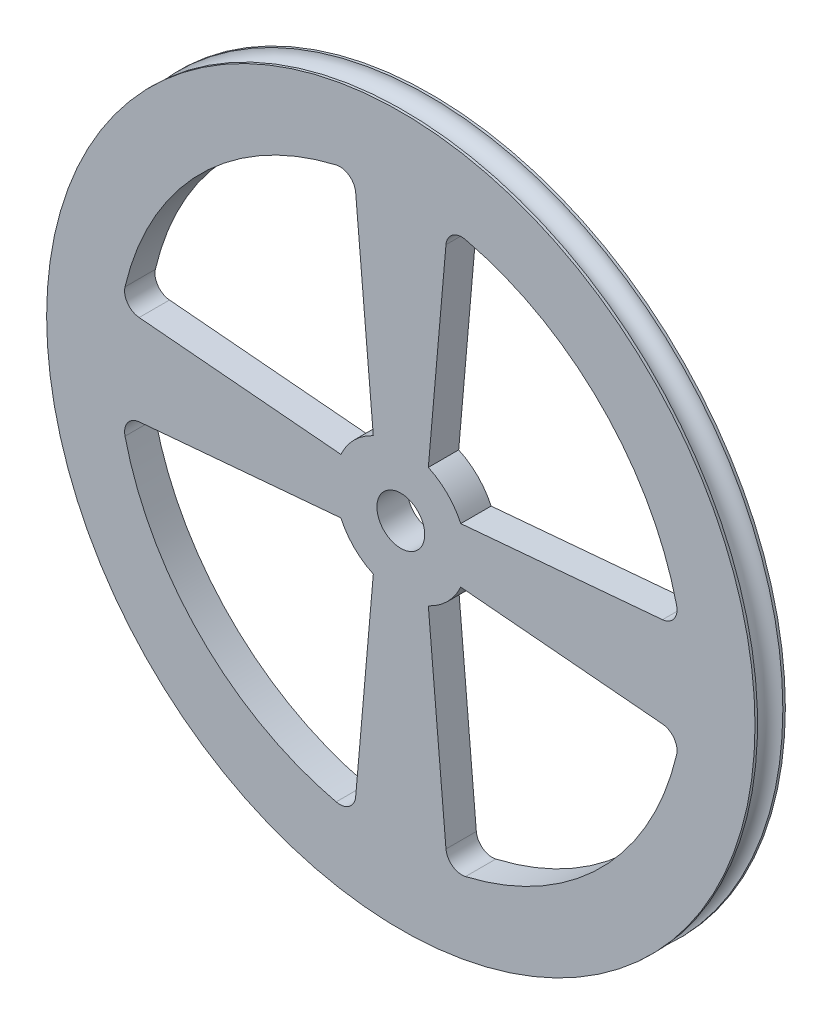
from build123d import *

# Parameters (mm, degrees)
SKETCH1_R           = 44.45
SKETCH1_R_2         = 3
BOSS_EXTRUDE1_DEPTH = 3.81
FILLET1_R           = 2
FILLET2_R           = 2
SKETCH3_R           = 1.5875


with BuildPart() as part:
    # Sketch1 → Boss-Extrude1 (new body)
    with BuildSketch(Plane.XY):
        Circle(SKETCH1_R)
        Circle(SKETCH1_R_2, mode=Mode.SUBTRACT)
        with BuildLine():
            Line((7.52236, -3.452121223), (35.063651683, -5.861672024))
            ThreePointArc((35.063651683, -5.861672024), (25.137808857, -25.137808857), (5.861672024, -35.063651683))
            Line((5.861672024, -35.063651683), (3.452121223, -7.52236))
            ThreePointArc((3.452121223, -7.52236), (5.852479855, -5.852479855), (7.52236, -3.452121223))
        make_face(mode=Mode.SUBTRACT)
        with BuildLine():
            Line((3.452121223, 7.52236), (5.861672024, 35.063651683))
            ThreePointArc((5.861672024, 35.063651683), (25.137808857, 25.137808857), (35.063651683, 5.861672024))
            Line((35.063651683, 5.861672024), (7.52236, 3.452121223))
            ThreePointArc((7.52236, 3.452121223), (5.852479855, 5.852479855), (3.452121223, 7.52236))
        make_face(mode=Mode.SUBTRACT)
        with BuildLine():
            Line((-3.452121223, 7.52236), (-5.861672024, 35.063651683))
            ThreePointArc((-5.861672024, 35.063651683), (-25.137808857, 25.137808857), (-35.063651683, 5.861672024))
            Line((-35.063651683, 5.861672024), (-7.52236, 3.452121223))
            ThreePointArc((-7.52236, 3.452121223), (-5.852479855, 5.852479855), (-3.452121223, 7.52236))
        make_face(mode=Mode.SUBTRACT)
        with BuildLine():
            Line((-3.452121223, -7.52236), (-5.861672024, -35.063651683))
            ThreePointArc((-5.861672024, -35.063651683), (-25.137808857, -25.137808857), (-35.063651683, -5.861672024))
            Line((-35.063651683, -5.861672024), (-7.52236, -3.452121223))
            ThreePointArc((-7.52236, -3.452121223), (-5.852479855, -5.852479855), (-3.452121223, -7.52236))
        make_face(mode=Mode.SUBTRACT)
    extrude(amount=BOSS_EXTRUDE1_DEPTH)

    # Fillet1
    fillet1_edges = [part.edges().sort_by_distance(p)[0] for p in [
        (35.063651683, -5.861672024, 1.905),
        (35.063651683, 5.861672024, 1.905),
    ]]
    fillet(fillet1_edges, radius=FILLET1_R)

    # Fillet2
    fillet2_edges = [part.edges().sort_by_distance(p)[0] for p in [
        (5.861672024, -35.063651683, 1.905),
        (-35.063651683, -5.861672024, 1.905),
        (-5.861672024, -35.063651683, 1.905),
        (5.861672024, 35.063651683, 1.905),
        (-5.861672024, 35.063651683, 1.905),
        (-35.063651683, 5.861672024, 1.905),
    ]]
    fillet(fillet2_edges, radius=FILLET2_R)

    # Sketch3 → Cut-Revolve1 (revolve, cut)
    with BuildSketch(Plane(origin=(0, 0, 0), x_dir=(1, 0, 0), z_dir=(0, 1, 0))):
        with Locations((-44.45, -1.905)):
            Circle(SKETCH3_R)
    revolve(axis=Axis((0, 0, 0), (0, 0, 1)), mode=Mode.SUBTRACT)


solid = part.part
